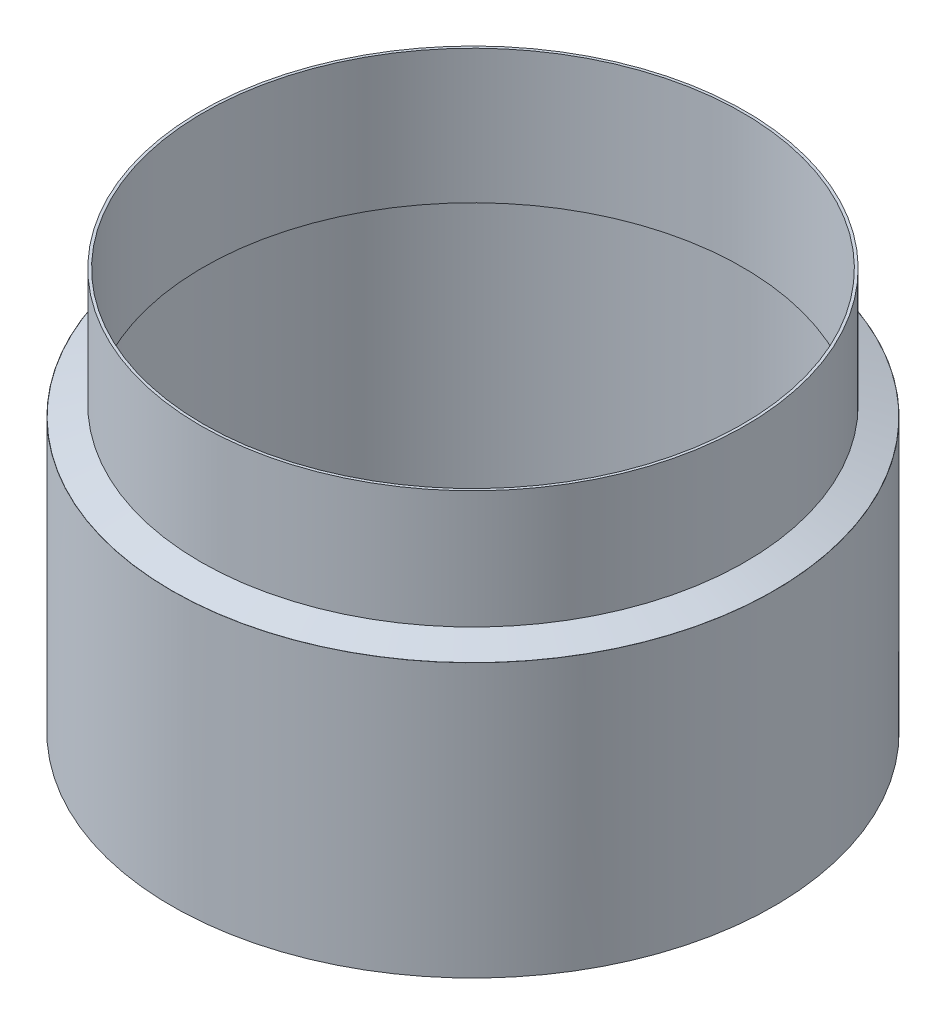
from build123d import *

# Parameters (mm, degrees)
SKETCH1_R           = 40.7
SKETCH1_R_2         = 40.3
BOSS_EXTRUDE1_DEPTH = 20
SKETCH2_R           = 45.025
SKETCH2_R_2         = 44.225
BOSS_EXTRUDE2_DEPTH = 40
SKETCH3_R           = 45.025
SKETCH3_R_2         = 40.7
BOSS_EXTRUDE3_DEPTH = 0.8
CHAMFER1_SIZE       = 4.3
CHAMFER1_SIZE2      = 1.565072007


with BuildPart() as part:
    # Sketch1 → Boss-Extrude1 (new body)
    with BuildSketch(Plane(origin=(0, 0, 0), x_dir=(1, 0, 0), z_dir=(0, 1, 0))):
        Circle(SKETCH1_R)
        Circle(SKETCH1_R_2, mode=Mode.SUBTRACT)
    extrude(amount=BOSS_EXTRUDE1_DEPTH)



with BuildPart() as body_2:
    # Sketch2 → Boss-Extrude2 (new body)
    with BuildSketch(Plane.XZ):
        Circle(SKETCH2_R)
        Circle(SKETCH2_R_2, mode=Mode.SUBTRACT)
    extrude(amount=BOSS_EXTRUDE2_DEPTH)


with BuildPart() as part_1:
    add(part.part)

    add(body_2.part)  # Boss-Extrude3 merges body 2
    # Sketch3 → Boss-Extrude3 (add)
    with BuildSketch(Plane(origin=(0, 0, 0), x_dir=(1, 0, 0), z_dir=(0, 1, 0))):
        Circle(SKETCH3_R)
        Circle(SKETCH3_R_2, mode=Mode.SUBTRACT)
    extrude(amount=BOSS_EXTRUDE3_DEPTH)

    # Chamfer1
    chamfer1_edges = [part_1.edges().sort_by_distance(p)[0] for p in [
        (-40.7, 0.8, 0),
    ]]
    chamfer1_side = [part_1.faces().sort_by_distance(p)[0] for p in [
        (-43.751500687, 0.8, 0),
    ]]
    chamfer(chamfer1_edges, length=CHAMFER1_SIZE, length2=CHAMFER1_SIZE2, reference=chamfer1_side[0])


solid = part_1.part
